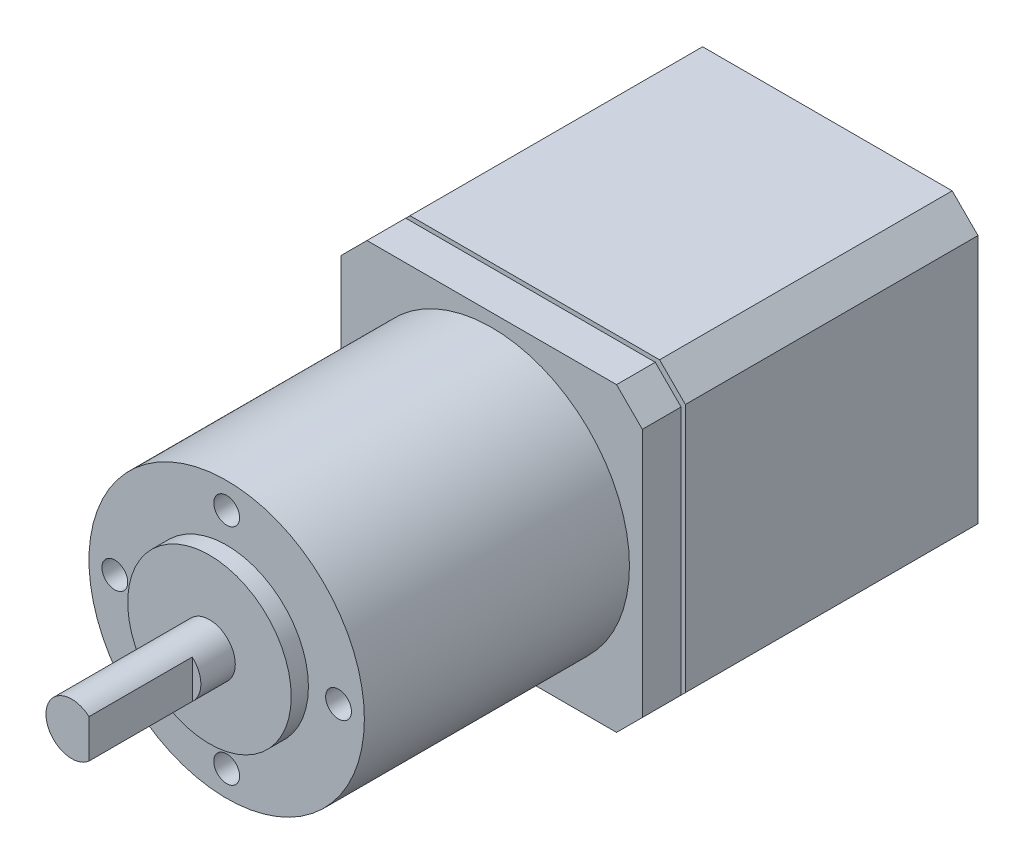
from build123d import *

# Parameters (mm, degrees)
SKIZZE1_W                       = 35
SKIZZE1_H                       = 35
AUFSATZ_LINEAR_AUSTRAGEN1_DEPTH = 34
SKIZZE2_R                       = 16
AUFSATZ_LINEAR_AUSTRAGEN2_DEPTH = 35.8
SKIZZE3_R                       = 9.5
AUFSATZ_LINEAR_AUSTRAGEN3_DEPTH = 2
SKIZZE4_R                       = 3
AUFSATZ_LINEAR_AUSTRAGEN4_DEPTH = 18
SKIZZE5_R                       = 1.5
SCHNITT_LINEAR_AUSTRAGEN1_DEPTH = 4
FASE1_SIZE                      = 3
AUFSATZ_LINEAR_START            = 0.5
AUFSATZ_LINEAR_AUSTRAGEN5_DEPTH = 4.5
SCHNITT_LINEAR_START            = -12
SCHNITT_LINEAR_AUSTRAGEN2_DEPTH = 12


with BuildPart() as part:
    # Skizze1 → Aufsatz-Linear austragen1 (new body)
    with BuildSketch(Plane.XY):
        Rectangle(SKIZZE1_W, SKIZZE1_H)
    extrude(amount=AUFSATZ_LINEAR_AUSTRAGEN1_DEPTH)

    # Skizze2 → Aufsatz-Linear austragen2 (add)
    with BuildSketch(Plane.XY.offset(34)):
        Circle(SKIZZE2_R)
    extrude(amount=AUFSATZ_LINEAR_AUSTRAGEN2_DEPTH)

    # Skizze3 → Aufsatz-Linear austragen3 (add)
    with BuildSketch(Plane.XY.offset(69.8)):
        Circle(SKIZZE3_R)
    extrude(amount=AUFSATZ_LINEAR_AUSTRAGEN3_DEPTH)

    # Skizze4 → Aufsatz-Linear austragen4 (add)
    with BuildSketch(Plane.XY.offset(69.8)):
        Circle(SKIZZE4_R)
    extrude(amount=AUFSATZ_LINEAR_AUSTRAGEN4_DEPTH)

    # Skizze5 → Schnitt-Linear austragen1 (cut)
    with BuildSketch(Plane.XY.offset(69.8)):
        with Locations((0, 13)):
            Circle(SKIZZE5_R)
        with Locations((13, 0)):
            Circle(SKIZZE5_R)
        with Locations((-13, 0)):
            Circle(SKIZZE5_R)
        with Locations((0, -13)):
            Circle(SKIZZE5_R)
    extrude(amount=-SCHNITT_LINEAR_AUSTRAGEN1_DEPTH, mode=Mode.SUBTRACT)

    # Fase1
    fase1_edges = [part.edges().sort_by_distance(p)[0] for p in [
        (-17.5, -17.5, 17),
        (17.5, -17.5, 17),
        (-17.5, 17.5, 17),
        (17.5, 17.5, 17),
    ]]
    chamfer(fase1_edges, length=FASE1_SIZE)

    # Skizze6 → Aufsatz-Linear austragen5 (add)
    with BuildSketch(Plane.XY.offset(34).offset(AUFSATZ_LINEAR_START)):
        Polygon((-17.5, 14.5), (-17.5, -14.5), (-14.5, -17.5), (14.5, -17.5), (17.5, -14.5), (17.5, 14.5), (14.5, 17.5), (-14.5, 17.5), align=None)
    extrude(amount=AUFSATZ_LINEAR_AUSTRAGEN5_DEPTH)

    # Skizze7 → Schnitt-Linear austragen2 (cut)
    with BuildSketch(Plane.XY.offset(87.8).offset(SCHNITT_LINEAR_START)):
        with BuildLine():
            Line((2, 2.236067977), (2, -2.236067977))
            ThreePointArc((2, -2.236067977), (3, 0), (2, 2.236067977))
        make_face()
    extrude(amount=SCHNITT_LINEAR_AUSTRAGEN2_DEPTH, mode=Mode.SUBTRACT)


solid = part.part
